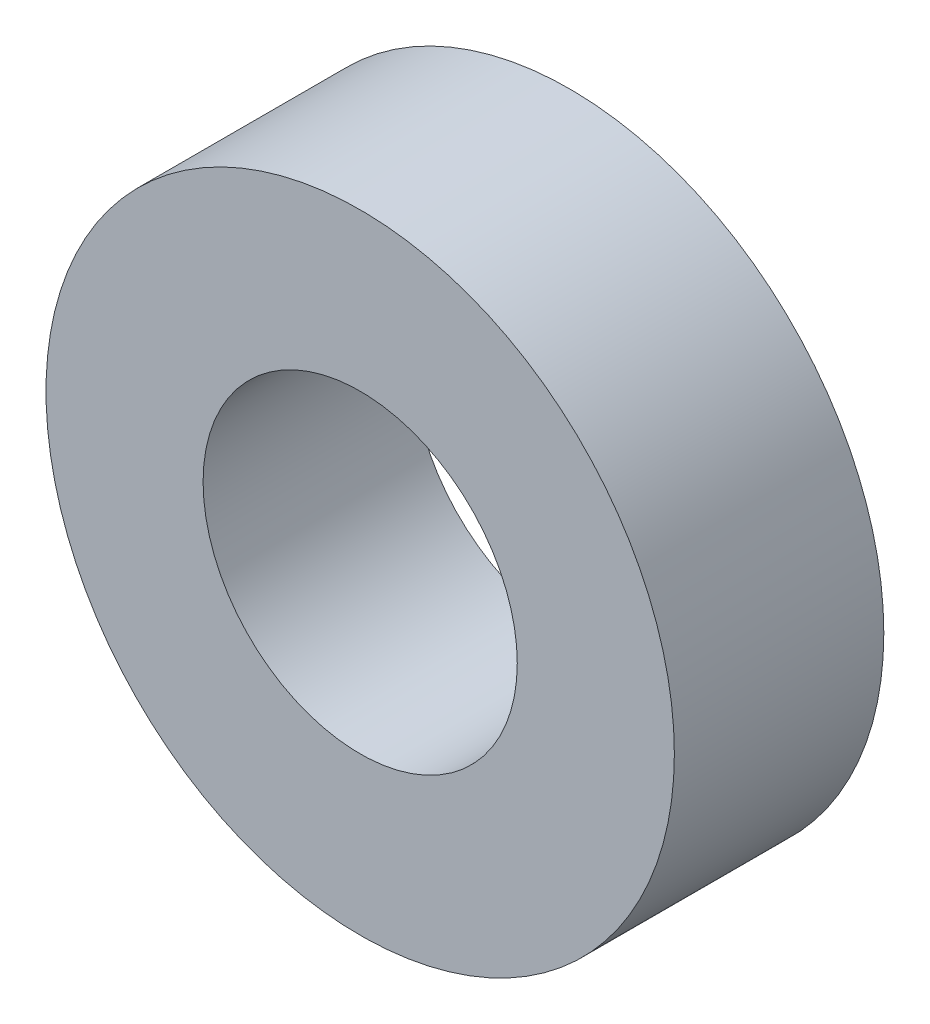
from build123d import *

# Parameters (mm, degrees)
SKETCH1_R           = 4.7625
SKETCH1_R_2         = 2.38125
BOSS_EXTRUDE1_DEPTH = 3.175


with BuildPart() as part:
    # Sketch1 → Boss-Extrude1 (new body)
    with BuildSketch(Plane.XY):
        with Locations((256.174942949, 227.325591656)):
            Circle(SKETCH1_R)
        with Locations((256.174942949, 227.325591656)):
            Circle(SKETCH1_R_2, mode=Mode.SUBTRACT)
    extrude(amount=BOSS_EXTRUDE1_DEPTH)


solid = part.part
